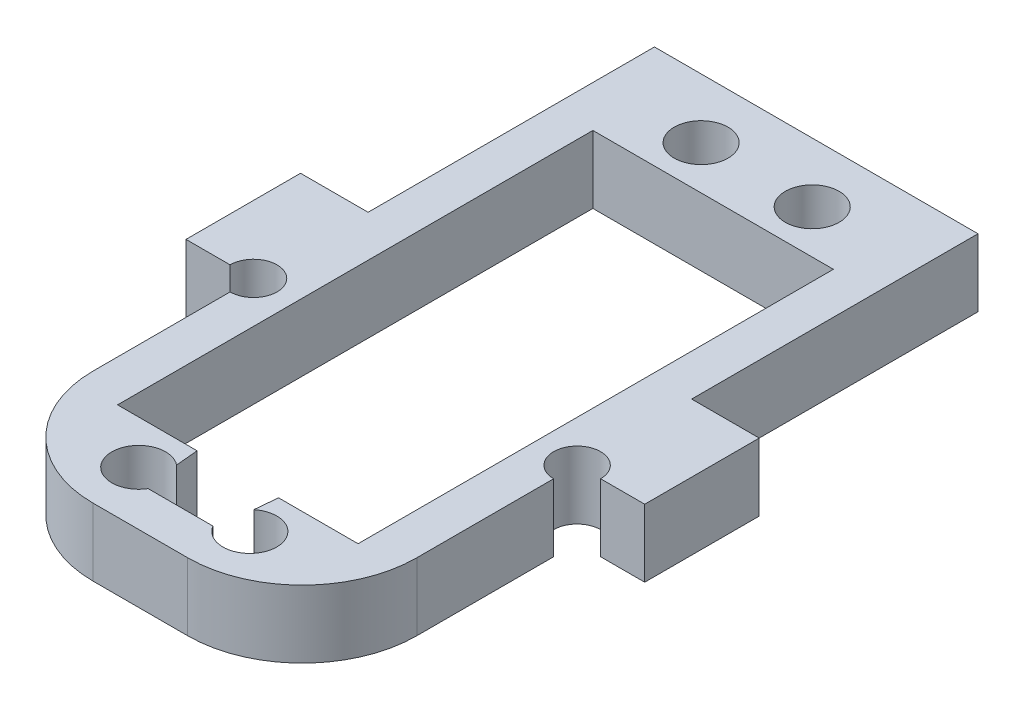
from build123d import *

# Parameters (mm, degrees)
SKETCH1_W           = 28.25
SKETCH1_H           = 58
BOSS_EXTRUDE1_DEPTH = 5.9
CUT_EXTRUDE1_REACH  = 7.9
SKETCH2_R           = 2.35
SKETCH2_W           = 20
SKETCH2_H           = 40.5
SKETCH3_W           = 5.9
SKETCH3_H           = 10
BOSS_EXTRUDE2_DEPTH = 5.9
CUT_EXTRUDE2_REACH  = 7.9
SKETCH4_R           = 2.05
CUT_EXTRUDE3_DEPTH  = 10
SKETCH6_W           = 28.25
SKETCH6_H           = 5.9
BOSS_EXTRUDE3_DEPTH = 1
FILLET1_R           = 10
CUT_EXTRUDE4_REACH  = 7.9
SKETCH7_W           = 21
SKETCH7_H           = 41.5


with BuildPart() as part:
    # Sketch1 → Boss-Extrude1 (new body)
    with BuildSketch(Plane(origin=(0, 0, 0), x_dir=(1, 0, 0), z_dir=(0, 1, 0))):
        with Locations((0, 1)):
            Rectangle(SKETCH1_W, SKETCH1_H)
    extrude(amount=BOSS_EXTRUDE1_DEPTH)

    # Sketch2 → Cut-Extrude1 (cut, up to next)
    with BuildSketch(Plane(origin=(0, 5.9, 0), x_dir=(1, 0, 0), z_dir=(0, 1, 0)), mode=Mode.PRIVATE) as cut_extrude1_sk1:
        with Locations((-4.85, -24.3)):
            Circle(SKETCH2_R)
    cut_extrude1_tool1 = extrude(cut_extrude1_sk1.sketch, amount=-CUT_EXTRUDE1_REACH, mode=Mode.PRIVATE) & part.part
    add(cut_extrude1_tool1.solids().sort_by_distance((-4.85, 5.9, 24.3))[0], mode=Mode.SUBTRACT)
    # Sketch2 → Cut-Extrude1 (cut, up to next)
    with BuildSketch(Plane(origin=(0, 5.9, 0), x_dir=(1, 0, 0), z_dir=(0, 1, 0)), mode=Mode.PRIVATE) as cut_extrude1_sk2:
        with Locations((-4.85, 24.8)):
            Circle(SKETCH2_R)
    cut_extrude1_tool2 = extrude(cut_extrude1_sk2.sketch, amount=-CUT_EXTRUDE1_REACH, mode=Mode.PRIVATE) & part.part
    add(cut_extrude1_tool2.solids().sort_by_distance((-4.85, 5.9, -24.8))[0], mode=Mode.SUBTRACT)
    # Sketch2 → Cut-Extrude1 (cut, up to next)
    with BuildSketch(Plane(origin=(0, 5.9, 0), x_dir=(1, 0, 0), z_dir=(0, 1, 0)), mode=Mode.PRIVATE) as cut_extrude1_sk3:
        with Locations((4.85, 24.8)):
            Circle(SKETCH2_R)
    cut_extrude1_tool3 = extrude(cut_extrude1_sk3.sketch, amount=-CUT_EXTRUDE1_REACH, mode=Mode.PRIVATE) & part.part
    add(cut_extrude1_tool3.solids().sort_by_distance((4.85, 5.9, -24.8))[0], mode=Mode.SUBTRACT)
    # Sketch2 → Cut-Extrude1 (cut, up to next)
    with BuildSketch(Plane(origin=(0, 5.9, 0), x_dir=(1, 0, 0), z_dir=(0, 1, 0)), mode=Mode.PRIVATE) as cut_extrude1_sk4:
        with Locations((4.85, -24.3)):
            Circle(SKETCH2_R)
    cut_extrude1_tool4 = extrude(cut_extrude1_sk4.sketch, amount=-CUT_EXTRUDE1_REACH, mode=Mode.PRIVATE) & part.part
    add(cut_extrude1_tool4.solids().sort_by_distance((4.85, 5.9, 24.3))[0], mode=Mode.SUBTRACT)
    # Sketch2 → Cut-Extrude1 (cut, up to next)
    with BuildSketch(Plane(origin=(0, 5.9, 0), x_dir=(1, 0, 0), z_dir=(0, 1, 0)), mode=Mode.PRIVATE) as cut_extrude1_sk5:
        with Locations((0, 0.25)):
            Rectangle(SKETCH2_W, SKETCH2_H)
    cut_extrude1_tool5 = extrude(cut_extrude1_sk5.sketch, amount=-CUT_EXTRUDE1_REACH, mode=Mode.PRIVATE) & part.part
    add(cut_extrude1_tool5.solids().sort_by_distance((0, 5.9, -0.25))[0], mode=Mode.SUBTRACT)

    # Sketch3 → Boss-Extrude2 (add)
    with BuildSketch(Plane(origin=(0, 5.9, 0), x_dir=(1, 0, 0), z_dir=(0, 1, 0))):
        with Locations((-17.075, 0)):
            Rectangle(SKETCH3_W, SKETCH3_H)
        with Locations((17.075, 0)):
            Rectangle(SKETCH3_W, SKETCH3_H)
    extrude(amount=-BOSS_EXTRUDE2_DEPTH)

    # Sketch4 → Cut-Extrude2 (cut, up to next)
    with BuildSketch(Plane(origin=(0, 5.9, 0), x_dir=(1, 0, 0), z_dir=(0, 1, 0)), mode=Mode.PRIVATE) as cut_extrude2_sk1:
        with Locations((-14.125, -5)):
            Circle(SKETCH4_R)
    cut_extrude2_tool1 = extrude(cut_extrude2_sk1.sketch, amount=-CUT_EXTRUDE2_REACH, mode=Mode.PRIVATE) & part.part
    add(cut_extrude2_tool1.solids().sort_by_distance((-14.125, 5.9, 5))[0], mode=Mode.SUBTRACT)
    # Sketch4 → Cut-Extrude2 (cut, up to next)
    with BuildSketch(Plane(origin=(0, 5.9, 0), x_dir=(1, 0, 0), z_dir=(0, 1, 0)), mode=Mode.PRIVATE) as cut_extrude2_sk2:
        with Locations((14.125, -5)):
            Circle(SKETCH4_R)
    cut_extrude2_tool2 = extrude(cut_extrude2_sk2.sketch, amount=-CUT_EXTRUDE2_REACH, mode=Mode.PRIVATE) & part.part
    add(cut_extrude2_tool2.solids().sort_by_distance((14.125, 5.9, 5))[0], mode=Mode.SUBTRACT)

    # Sketch5 → Cut-Extrude3 (cut)
    with BuildSketch(Plane(origin=(0, 5.9, 0), x_dir=(1, 0, 0), z_dir=(0, 1, 0))):
        Polygon((3.1, -20), (3.6, -20), (3.1, -25.5), (-3.1, -25.5), (-3.6, -20), (-3.1, -20), (0, -20), align=None)
    extrude(amount=-CUT_EXTRUDE3_DEPTH, mode=Mode.SUBTRACT)

    # Sketch6 → Boss-Extrude3 (add)
    with BuildSketch(Plane.XY.offset(28)):
        with Locations((0, 2.95)):
            Rectangle(SKETCH6_W, SKETCH6_H)
    extrude(amount=BOSS_EXTRUDE3_DEPTH)

    # Fillet1
    fillet1_edges = [part.edges().sort_by_distance(p)[0] for p in [
        (-14.125, 2.95, 29),
        (14.125, 2.95, 29),
    ]]
    fillet(fillet1_edges, radius=FILLET1_R)

    # Sketch7 → Cut-Extrude4 (cut, up to next)
    with BuildSketch(Plane(origin=(0, 5.9, 0), x_dir=(1, 0, 0), z_dir=(0, 1, 0)), mode=Mode.PRIVATE) as cut_extrude4_sk1:
        with Locations((0, 0.25)):
            Rectangle(SKETCH7_W, SKETCH7_H)
    cut_extrude4_tool1 = extrude(cut_extrude4_sk1.sketch, amount=-CUT_EXTRUDE4_REACH, mode=Mode.PRIVATE) & part.part
    add(cut_extrude4_tool1.solids().sort_by_distance((0, 5.9, -0.25))[0], mode=Mode.SUBTRACT)


solid = part.part
